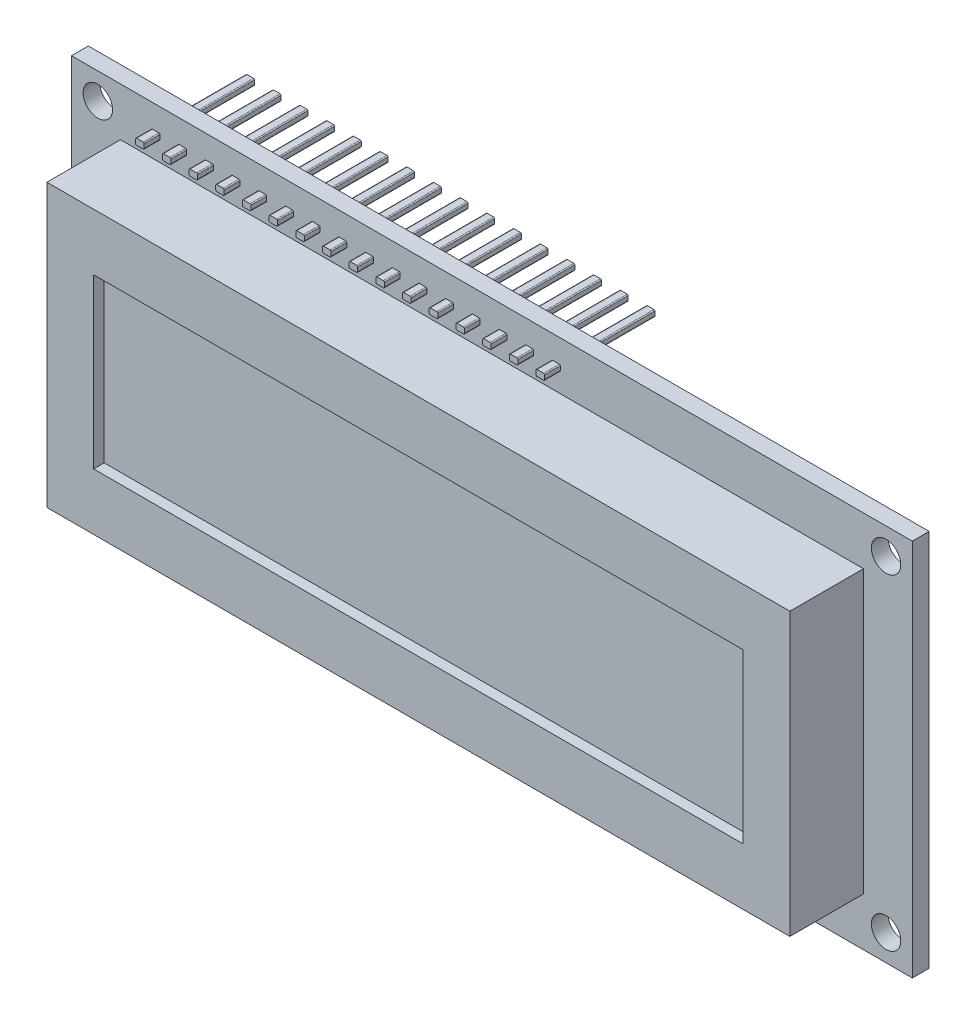
from build123d import *

# Parameters (mm, degrees)
ESQUISSE1_W             = 80
ESQUISSE1_H             = 36
ESQUISSE1_R             = 1.4
BOSS_EXTRU_1_DEPTH      = 1.6
ESQUISSE2_W             = 70.7
ESQUISSE2_H             = 26.8
BOSS_EXTRU_2_DEPTH      = 7
ESQUISSE3_W             = 61.8
ESQUISSE3_H             = 16
ENL_V_MAT_EXTRU_1_DEPTH = 1
BOSS_EXTRU_3_DEPTH      = 1.5
BOSS_EXTRU_3_DEPTH_BACK = 9


with BuildPart() as part:
    # Esquisse1 → Boss.-Extru.1 (new body)
    with BuildSketch(Plane.XY):
        with Locations((40, 18)):
            Rectangle(ESQUISSE1_W, ESQUISSE1_H)
        with Locations((2.5, 33.5)):
            Circle(ESQUISSE1_R, mode=Mode.SUBTRACT)
        with Locations((77.5, 33.5)):
            Circle(ESQUISSE1_R, mode=Mode.SUBTRACT)
        with Locations((77.5, 2.5)):
            Circle(ESQUISSE1_R, mode=Mode.SUBTRACT)
        with Locations((2.5, 2.5)):
            Circle(ESQUISSE1_R, mode=Mode.SUBTRACT)
    extrude(amount=BOSS_EXTRU_1_DEPTH)

    # Esquisse2 → Boss.-Extru.2 (add)
    with BuildSketch(Plane.XY.offset(1.6)):
        with Locations((40, 18)):
            Rectangle(ESQUISSE2_W, ESQUISSE2_H)
    extrude(amount=BOSS_EXTRU_2_DEPTH)

    # Esquisse3 → Enlèv. mat.-Extru.1 (cut)
    with BuildSketch(Plane.XY.offset(8.6)):
        with Locations((40, 18)):
            Rectangle(ESQUISSE3_W, ESQUISSE3_H)
    extrude(amount=-ENL_V_MAT_EXTRU_1_DEPTH, mode=Mode.SUBTRACT)

    # Esquisse4 → Boss.-Extru.3 (add, two sides)
    with BuildSketch(Plane.XY.offset(1.6)) as boss_extru_3_sk:
        with BuildLine():
            Line((7.694800645, 33.792939384), (8.305199355, 33.792939384))
            ThreePointArc((8.305199355, 33.792939384), (8.375910033, 33.763650062), (8.405199355, 33.692939384))
            Line((8.405199355, 33.692939384), (8.405199355, 33.307060616))
            ThreePointArc((8.405199355, 33.307060616), (8.375910033, 33.236349938), (8.305199355, 33.207060616))
            Line((8.305199355, 33.207060616), (7.694800645, 33.207060616))
            ThreePointArc((7.694800645, 33.207060616), (7.624089967, 33.236349938), (7.594800645, 33.307060616))
            Line((7.594800645, 33.307060616), (7.594800645, 33.692939384))
            ThreePointArc((7.594800645, 33.692939384), (7.624089967, 33.763650062), (7.694800645, 33.792939384))
        make_face()
        with BuildLine():
            Line((10.234800645, 33.792939384), (10.845199355, 33.792939384))
            ThreePointArc((10.845199355, 33.792939384), (10.915910033, 33.763650062), (10.945199355, 33.692939384))
            Line((10.945199355, 33.692939384), (10.945199355, 33.307060616))
            ThreePointArc((10.945199355, 33.307060616), (10.915910033, 33.236349938), (10.845199355, 33.207060616))
            Line((10.845199355, 33.207060616), (10.234800645, 33.207060616))
            ThreePointArc((10.234800645, 33.207060616), (10.164089967, 33.236349938), (10.134800645, 33.307060616))
            Line((10.134800645, 33.307060616), (10.134800645, 33.692939384))
            ThreePointArc((10.134800645, 33.692939384), (10.164089967, 33.763650062), (10.234800645, 33.792939384))
        make_face()
        with BuildLine():
            Line((12.774800645, 33.792939384), (13.385199355, 33.792939384))
            ThreePointArc((13.385199355, 33.792939384), (13.455910033, 33.763650062), (13.485199355, 33.692939384))
            Line((13.485199355, 33.692939384), (13.485199355, 33.307060616))
            ThreePointArc((13.485199355, 33.307060616), (13.455910033, 33.236349938), (13.385199355, 33.207060616))
            Line((13.385199355, 33.207060616), (12.774800645, 33.207060616))
            ThreePointArc((12.774800645, 33.207060616), (12.704089967, 33.236349938), (12.674800645, 33.307060616))
            Line((12.674800645, 33.307060616), (12.674800645, 33.692939384))
            ThreePointArc((12.674800645, 33.692939384), (12.704089967, 33.763650062), (12.774800645, 33.792939384))
        make_face()
        with BuildLine():
            Line((15.314800645, 33.792939384), (15.925199355, 33.792939384))
            ThreePointArc((15.925199355, 33.792939384), (15.995910033, 33.763650062), (16.025199355, 33.692939384))
            Line((16.025199355, 33.692939384), (16.025199355, 33.307060616))
            ThreePointArc((16.025199355, 33.307060616), (15.995910033, 33.236349938), (15.925199355, 33.207060616))
            Line((15.925199355, 33.207060616), (15.314800645, 33.207060616))
            ThreePointArc((15.314800645, 33.207060616), (15.244089967, 33.236349938), (15.214800645, 33.307060616))
            Line((15.214800645, 33.307060616), (15.214800645, 33.692939384))
            ThreePointArc((15.214800645, 33.692939384), (15.244089967, 33.763650062), (15.314800645, 33.792939384))
        make_face()
        with BuildLine():
            Line((17.854800645, 33.792939384), (18.465199355, 33.792939384))
            ThreePointArc((18.465199355, 33.792939384), (18.535910033, 33.763650062), (18.565199355, 33.692939384))
            Line((18.565199355, 33.692939384), (18.565199355, 33.307060616))
            ThreePointArc((18.565199355, 33.307060616), (18.535910033, 33.236349938), (18.465199355, 33.207060616))
            Line((18.465199355, 33.207060616), (17.854800645, 33.207060616))
            ThreePointArc((17.854800645, 33.207060616), (17.784089967, 33.236349938), (17.754800645, 33.307060616))
            Line((17.754800645, 33.307060616), (17.754800645, 33.692939384))
            ThreePointArc((17.754800645, 33.692939384), (17.784089967, 33.763650062), (17.854800645, 33.792939384))
        make_face()
        with BuildLine():
            Line((20.394800645, 33.792939384), (21.005199355, 33.792939384))
            ThreePointArc((21.005199355, 33.792939384), (21.075910033, 33.763650062), (21.105199355, 33.692939384))
            Line((21.105199355, 33.692939384), (21.105199355, 33.307060616))
            ThreePointArc((21.105199355, 33.307060616), (21.075910033, 33.236349938), (21.005199355, 33.207060616))
            Line((21.005199355, 33.207060616), (20.394800645, 33.207060616))
            ThreePointArc((20.394800645, 33.207060616), (20.324089967, 33.236349938), (20.294800645, 33.307060616))
            Line((20.294800645, 33.307060616), (20.294800645, 33.692939384))
            ThreePointArc((20.294800645, 33.692939384), (20.324089967, 33.763650062), (20.394800645, 33.792939384))
        make_face()
        with BuildLine():
            Line((22.934800645, 33.792939384), (23.545199355, 33.792939384))
            ThreePointArc((23.545199355, 33.792939384), (23.615910033, 33.763650062), (23.645199355, 33.692939384))
            Line((23.645199355, 33.692939384), (23.645199355, 33.307060616))
            ThreePointArc((23.645199355, 33.307060616), (23.615910033, 33.236349938), (23.545199355, 33.207060616))
            Line((23.545199355, 33.207060616), (22.934800645, 33.207060616))
            ThreePointArc((22.934800645, 33.207060616), (22.864089967, 33.236349938), (22.834800645, 33.307060616))
            Line((22.834800645, 33.307060616), (22.834800645, 33.692939384))
            ThreePointArc((22.834800645, 33.692939384), (22.864089967, 33.763650062), (22.934800645, 33.792939384))
        make_face()
        with BuildLine():
            Line((25.474800645, 33.792939384), (26.085199355, 33.792939384))
            ThreePointArc((26.085199355, 33.792939384), (26.155910033, 33.763650062), (26.185199355, 33.692939384))
            Line((26.185199355, 33.692939384), (26.185199355, 33.307060616))
            ThreePointArc((26.185199355, 33.307060616), (26.155910033, 33.236349938), (26.085199355, 33.207060616))
            Line((26.085199355, 33.207060616), (25.474800645, 33.207060616))
            ThreePointArc((25.474800645, 33.207060616), (25.404089967, 33.236349938), (25.374800645, 33.307060616))
            Line((25.374800645, 33.307060616), (25.374800645, 33.692939384))
            ThreePointArc((25.374800645, 33.692939384), (25.404089967, 33.763650062), (25.474800645, 33.792939384))
        make_face()
        with BuildLine():
            Line((28.014800645, 33.792939384), (28.625199355, 33.792939384))
            ThreePointArc((28.625199355, 33.792939384), (28.695910033, 33.763650062), (28.725199355, 33.692939384))
            Line((28.725199355, 33.692939384), (28.725199355, 33.307060616))
            ThreePointArc((28.725199355, 33.307060616), (28.695910033, 33.236349938), (28.625199355, 33.207060616))
            Line((28.625199355, 33.207060616), (28.014800645, 33.207060616))
            ThreePointArc((28.014800645, 33.207060616), (27.944089967, 33.236349938), (27.914800645, 33.307060616))
            Line((27.914800645, 33.307060616), (27.914800645, 33.692939384))
            ThreePointArc((27.914800645, 33.692939384), (27.944089967, 33.763650062), (28.014800645, 33.792939384))
        make_face()
        with BuildLine():
            Line((30.554800645, 33.792939384), (31.165199355, 33.792939384))
            ThreePointArc((31.165199355, 33.792939384), (31.235910033, 33.763650062), (31.265199355, 33.692939384))
            Line((31.265199355, 33.692939384), (31.265199355, 33.307060616))
            ThreePointArc((31.265199355, 33.307060616), (31.235910033, 33.236349938), (31.165199355, 33.207060616))
            Line((31.165199355, 33.207060616), (30.554800645, 33.207060616))
            ThreePointArc((30.554800645, 33.207060616), (30.484089967, 33.236349938), (30.454800645, 33.307060616))
            Line((30.454800645, 33.307060616), (30.454800645, 33.692939384))
            ThreePointArc((30.454800645, 33.692939384), (30.484089967, 33.763650062), (30.554800645, 33.792939384))
        make_face()
        with BuildLine():
            Line((33.094800645, 33.792939384), (33.705199355, 33.792939384))
            ThreePointArc((33.705199355, 33.792939384), (33.775910033, 33.763650062), (33.805199355, 33.692939384))
            Line((33.805199355, 33.692939384), (33.805199355, 33.307060616))
            ThreePointArc((33.805199355, 33.307060616), (33.775910033, 33.236349938), (33.705199355, 33.207060616))
            Line((33.705199355, 33.207060616), (33.094800645, 33.207060616))
            ThreePointArc((33.094800645, 33.207060616), (33.024089967, 33.236349938), (32.994800645, 33.307060616))
            Line((32.994800645, 33.307060616), (32.994800645, 33.692939384))
            ThreePointArc((32.994800645, 33.692939384), (33.024089967, 33.763650062), (33.094800645, 33.792939384))
        make_face()
        with BuildLine():
            Line((35.634800645, 33.792939384), (36.245199355, 33.792939384))
            ThreePointArc((36.245199355, 33.792939384), (36.315910033, 33.763650062), (36.345199355, 33.692939384))
            Line((36.345199355, 33.692939384), (36.345199355, 33.307060616))
            ThreePointArc((36.345199355, 33.307060616), (36.315910033, 33.236349938), (36.245199355, 33.207060616))
            Line((36.245199355, 33.207060616), (35.634800645, 33.207060616))
            ThreePointArc((35.634800645, 33.207060616), (35.564089967, 33.236349938), (35.534800645, 33.307060616))
            Line((35.534800645, 33.307060616), (35.534800645, 33.692939384))
            ThreePointArc((35.534800645, 33.692939384), (35.564089967, 33.763650062), (35.634800645, 33.792939384))
        make_face()
        with BuildLine():
            Line((38.174800645, 33.792939384), (38.785199355, 33.792939384))
            ThreePointArc((38.785199355, 33.792939384), (38.855910033, 33.763650062), (38.885199355, 33.692939384))
            Line((38.885199355, 33.692939384), (38.885199355, 33.307060616))
            ThreePointArc((38.885199355, 33.307060616), (38.855910033, 33.236349938), (38.785199355, 33.207060616))
            Line((38.785199355, 33.207060616), (38.174800645, 33.207060616))
            ThreePointArc((38.174800645, 33.207060616), (38.104089967, 33.236349938), (38.074800645, 33.307060616))
            Line((38.074800645, 33.307060616), (38.074800645, 33.692939384))
            ThreePointArc((38.074800645, 33.692939384), (38.104089967, 33.763650062), (38.174800645, 33.792939384))
        make_face()
        with BuildLine():
            Line((40.714800645, 33.792939384), (41.325199355, 33.792939384))
            ThreePointArc((41.325199355, 33.792939384), (41.395910033, 33.763650062), (41.425199355, 33.692939384))
            Line((41.425199355, 33.692939384), (41.425199355, 33.307060616))
            ThreePointArc((41.425199355, 33.307060616), (41.395910033, 33.236349938), (41.325199355, 33.207060616))
            Line((41.325199355, 33.207060616), (40.714800645, 33.207060616))
            ThreePointArc((40.714800645, 33.207060616), (40.644089967, 33.236349938), (40.614800645, 33.307060616))
            Line((40.614800645, 33.307060616), (40.614800645, 33.692939384))
            ThreePointArc((40.614800645, 33.692939384), (40.644089967, 33.763650062), (40.714800645, 33.792939384))
        make_face()
        with BuildLine():
            Line((43.254800645, 33.792939384), (43.865199355, 33.792939384))
            ThreePointArc((43.865199355, 33.792939384), (43.935910033, 33.763650062), (43.965199355, 33.692939384))
            Line((43.965199355, 33.692939384), (43.965199355, 33.307060616))
            ThreePointArc((43.965199355, 33.307060616), (43.935910033, 33.236349938), (43.865199355, 33.207060616))
            Line((43.865199355, 33.207060616), (43.254800645, 33.207060616))
            ThreePointArc((43.254800645, 33.207060616), (43.184089967, 33.236349938), (43.154800645, 33.307060616))
            Line((43.154800645, 33.307060616), (43.154800645, 33.692939384))
            ThreePointArc((43.154800645, 33.692939384), (43.184089967, 33.763650062), (43.254800645, 33.792939384))
        make_face()
        with BuildLine():
            Line((45.794800645, 33.792939384), (46.405199355, 33.792939384))
            ThreePointArc((46.405199355, 33.792939384), (46.475910033, 33.763650062), (46.505199355, 33.692939384))
            Line((46.505199355, 33.692939384), (46.505199355, 33.307060616))
            ThreePointArc((46.505199355, 33.307060616), (46.475910033, 33.236349938), (46.405199355, 33.207060616))
            Line((46.405199355, 33.207060616), (45.794800645, 33.207060616))
            ThreePointArc((45.794800645, 33.207060616), (45.724089967, 33.236349938), (45.694800645, 33.307060616))
            Line((45.694800645, 33.307060616), (45.694800645, 33.692939384))
            ThreePointArc((45.694800645, 33.692939384), (45.724089967, 33.763650062), (45.794800645, 33.792939384))
        make_face()
    extrude(amount=BOSS_EXTRU_3_DEPTH)
    extrude(boss_extru_3_sk.sketch, amount=-BOSS_EXTRU_3_DEPTH_BACK)


solid = part.part
